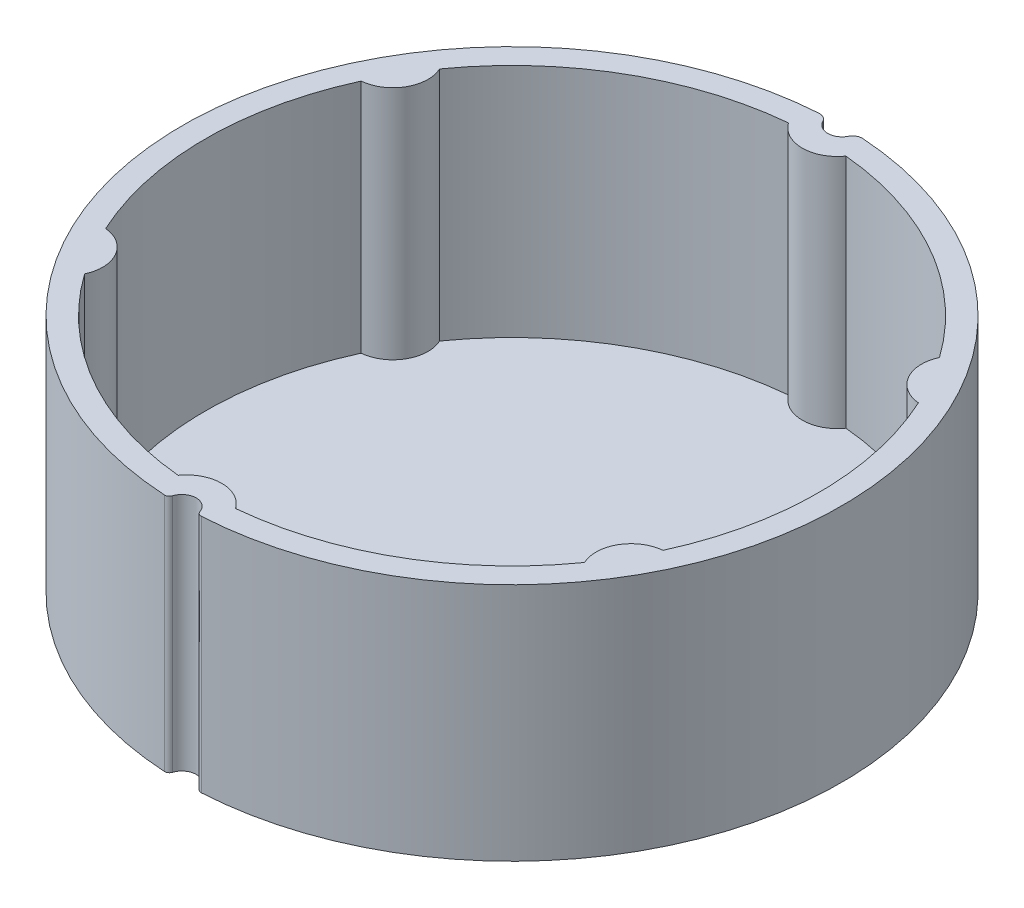
from build123d import *

# Parameters (mm, degrees)
BOSS_EXTRUDE1_DEPTH = 25
BOSS_EXTRUDE2_DEPTH = 25
SKETCH6_R           = 32
CUT_EXTRUDE2_DEPTH  = 24.6
BOSS_EXTRUDE5_DEPTH = 24.6
CIRPATTERN1_COUNT   = 6


with BuildPart() as part:
    # Sketch1 → Boss-Extrude1 (new body)
    with BuildSketch(Plane(origin=(0, 0, 0), x_dir=(1, 0, 0), z_dir=(0, 1, 0))):
        with BuildLine():
            ThreePointArc((1.418185365, -33.998799682), (1.610940688, -34.258772233), (1.922534331, -34.346235045))
            ThreePointArc((1.922534331, -34.346235045), (34.399487229, -0.187825316), (2.297477624, 34.323193275))
            ThreePointArc((2.297477624, 34.323193275), (1.735753357, 34.194354817), (1.33841429, 33.776916))
            ThreePointArc((1.33841429, 33.776916), (0, 32.954150957), (-1.33841429, 33.776916))
            ThreePointArc((-1.33841429, 33.776916), (-1.735753357, 34.194354817), (-2.297477624, 34.323193275))
            ThreePointArc((-2.297477624, 34.323193275), (-34.399545597, -0.176812713), (-1.944525024, -34.344997051))
            ThreePointArc((-1.944525024, -34.344997051), (-1.632875445, -34.257733763), (-1.439953708, -33.997884682))
            ThreePointArc((-1.439953708, -33.997884682), (-0.010549885, -32.954149268), (1.418185365, -33.998799682))
        make_face()
        with BuildLine():
            Line((-2.417, 3.18717916), (0, 3.18717916))
            Line((0, 3.18717916), (2.417, 3.18717916))
            ThreePointArc((2.417, 3.18717916), (0, -4), (-2.417, 3.18717916))
        make_face(mode=Mode.SUBTRACT)
    extrude(amount=BOSS_EXTRUDE1_DEPTH)

    # Sketch5 → Boss-Extrude2 (add)
    with BuildSketch(Plane.XZ):
        with BuildLine():
            Line((-2.732678298, -4.18717916), (0, -4.18717916))
            Line((0, -4.18717916), (2.732678298, -4.18717916))
            ThreePointArc((2.732678298, -4.18717916), (0, 5), (-2.732678298, -4.18717916))
        make_face()
    extrude(amount=-BOSS_EXTRUDE2_DEPTH)

    # Sketch6 → Cut-Extrude2 (cut)
    with BuildSketch(Plane(origin=(0, 25, 0), x_dir=(1, 0, 0), z_dir=(0, 1, 0))):
        Circle(SKETCH6_R)
    extrude(amount=-CUT_EXTRUDE2_DEPTH, mode=Mode.SUBTRACT)

    # Sketch8 → Boss-Extrude5 (add)
    with BuildSketch(Plane(origin=(0, 0.4, 0), x_dir=(1, 0, 0), z_dir=(0, 1, 0))):
        with BuildLine():
            ThreePointArc((3, 31.859064644), (0, 30.3), (-3, 31.859064644))
            ThreePointArc((-3, 31.859064644), (0, 32), (3, 31.859064644))
        make_face()
    boss_extrude5 = extrude(amount=BOSS_EXTRUDE5_DEPTH)

    # CirPattern1: Boss-Extrude5 ×6 about axis
    cirpattern1_axis = Axis((0, 0, 0), (0, 1, 0))
    for i in range(1, CIRPATTERN1_COUNT):
        add(boss_extrude5.rotate(cirpattern1_axis, i * 360 / CIRPATTERN1_COUNT))


solid = part.part
